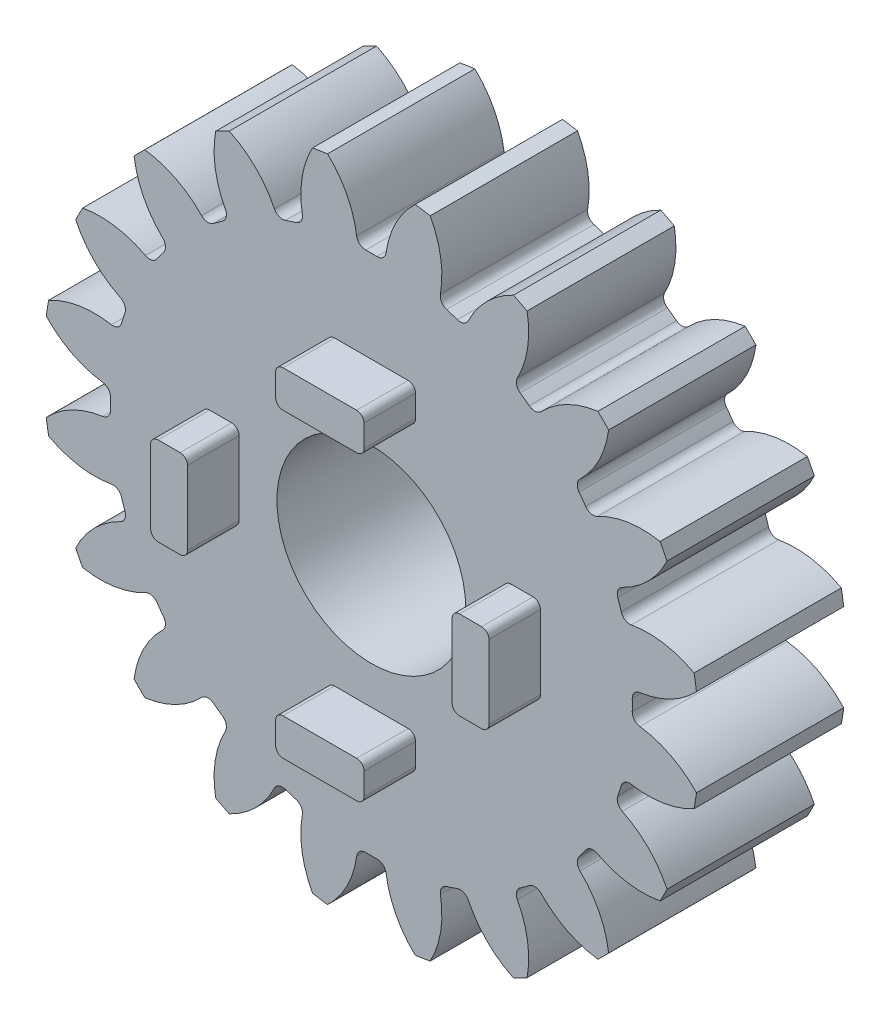
from build123d import *

# Parameters (mm, degrees)
SKETCH1_R                = 22.275
BOSS_EXTRUDE1_DEPTH      = 10
CUT_EXTRUDE1_DEPTH       = 11
FILLET1_R                = 0.6075
CIRPATTERN5_COUNT        = 20
FILLET1_OF_CIRPATTERN5_R = 0.6075
SKETCH3_R                = 6.4135
CUT_EXTRUDE2_DEPTH       = 10
SKETCH4_W                = 6
SKETCH4_H                = 2.5
BOSS_EXTRUDE2_DEPTH      = 3.5
FILLET2_R                = 0.5
CIRPATTERN6_COUNT        = 4
FILLET2_OF_CIRPATTERN6_R = 0.5


with BuildPart() as part:
    # Sketch1 → Boss-Extrude1 (new body)
    with BuildSketch(Plane.XY):
        Circle(SKETCH1_R)
    extrude(amount=BOSS_EXTRUDE1_DEPTH)

    # Sketch2 → Cut-Extrude1 (cut, through all)
    with BuildSketch(Plane.XY):
        with BuildLine():
            ThreePointArc((-3.116364363, 22.207406381), (-1.57918473, 20.167679259), (-0.945185984, 17.69352212))
            ThreePointArc((-0.945185984, 17.69352212), (0, 17.71875), (0.945185984, 17.69352212))
            ThreePointArc((0.945185984, 17.69352212), (1.57918473, 20.167679259), (3.116364363, 22.207406381))
            ThreePointArc((3.116364363, 22.207406381), (0, 22.425), (-3.116364363, 22.207406381))
        make_face()
    cut_extrude1 = extrude(amount=CUT_EXTRUDE1_DEPTH, mode=Mode.SUBTRACT)

    # Fillet1
    fillet1_edges = [part.edges().sort_by_distance(p)[0] for p in [
        (0.945185984, 17.69352212, 5),
        (-0.945185984, 17.69352212, 5),
    ]]
    fillet(fillet1_edges, radius=FILLET1_R)

    # CirPattern5: Cut-Extrude1 ×20 about axis
    cirpattern5_axis = Axis((0, 0, 0), (0, 0, 1))
    for i in range(1, CIRPATTERN5_COUNT):
        add(cut_extrude1.rotate(cirpattern5_axis, i * 360 / CIRPATTERN5_COUNT), mode=Mode.SUBTRACT)

    # Fillet1 of CirPattern5
    fillet1_of_cirpattern5_edges = [part.edges().sort_by_distance(p)[0] for p in [
        (-4.568673736, 17.11961804, 5),
        (-6.366524315, 16.535460977, 5),
        (-9.63531984, 14.869926468, 5),
        (-11.164662887, 13.758793704, 5),
        (-13.758793704, 11.164662887, 5),
        (-14.869926468, 9.63531984, 5),
        (-16.535460977, 6.366524315, 5),
        (-17.11961804, 4.568673736, 5),
        (-17.69352212, 0.945185984, 5),
        (-17.69352212, -0.945185984, 5),
        (-17.11961804, -4.568673736, 5),
        (-16.535460977, -6.366524315, 5),
        (-14.869926468, -9.63531984, 5),
        (-13.758793704, -11.164662887, 5),
        (-11.164662887, -13.758793704, 5),
        (-9.63531984, -14.869926468, 5),
        (-6.366524315, -16.535460977, 5),
        (-4.568673736, -17.11961804, 5),
        (-0.945185984, -17.69352212, 5),
        (0.945185984, -17.69352212, 5),
        (4.568673736, -17.11961804, 5),
        (6.366524315, -16.535460977, 5),
        (9.63531984, -14.869926468, 5),
        (11.164662887, -13.758793704, 5),
        (13.758793704, -11.164662887, 5),
        (14.869926468, -9.63531984, 5),
        (16.535460977, -6.366524315, 5),
        (17.11961804, -4.568673736, 5),
        (17.69352212, -0.945185984, 5),
        (17.69352212, 0.945185984, 5),
        (17.11961804, 4.568673736, 5),
        (16.535460977, 6.366524315, 5),
        (14.869926468, 9.63531984, 5),
        (13.758793704, 11.164662887, 5),
        (11.164662887, 13.758793704, 5),
        (9.63531984, 14.869926468, 5),
        (6.366524315, 16.535460977, 5),
        (4.568673736, 17.11961804, 5),
    ]]
    fillet(fillet1_of_cirpattern5_edges, radius=FILLET1_OF_CIRPATTERN5_R)

    # Sketch3 → Cut-Extrude2 (cut)
    with BuildSketch(Plane.XY.offset(10)):
        Circle(SKETCH3_R)
    extrude(amount=-CUT_EXTRUDE2_DEPTH, mode=Mode.SUBTRACT)

    # Sketch4 → Boss-Extrude2 (add)
    with BuildSketch(Plane.XY.offset(10)):
        with Locations((0, 10.234341946)):
            Rectangle(SKETCH4_W, SKETCH4_H)
    boss_extrude2 = extrude(amount=BOSS_EXTRUDE2_DEPTH)

    # Fillet2
    fillet2_edges = [part.edges().sort_by_distance(p)[0] for p in [
        (-3, 11.484341946, 11.75),
        (-3, 8.984341946, 11.75),
        (3, 8.984341946, 11.75),
        (3, 11.484341946, 11.75),
    ]]
    fillet(fillet2_edges, radius=FILLET2_R)

    # CirPattern6: Boss-Extrude2 ×4 about axis
    cirpattern6_axis = Axis((0, 0, 0), (0, 0, 1))
    for i in range(1, CIRPATTERN6_COUNT):
        add(boss_extrude2.rotate(cirpattern6_axis, i * 360 / CIRPATTERN6_COUNT))

    # Fillet2 of CirPattern6
    fillet2_of_cirpattern6_edges = [part.edges().sort_by_distance(p)[0] for p in [
        (-11.484341946, -3, 11.75),
        (-8.984341946, -3, 11.75),
        (-8.984341946, 3, 11.75),
        (-11.484341946, 3, 11.75),
        (3, -11.484341946, 11.75),
        (3, -8.984341946, 11.75),
        (-3, -8.984341946, 11.75),
        (-3, -11.484341946, 11.75),
        (11.484341946, 3, 11.75),
        (8.984341946, 3, 11.75),
        (8.984341946, -3, 11.75),
        (11.484341946, -3, 11.75),
    ]]
    fillet(fillet2_of_cirpattern6_edges, radius=FILLET2_OF_CIRPATTERN6_R)


solid = part.part
